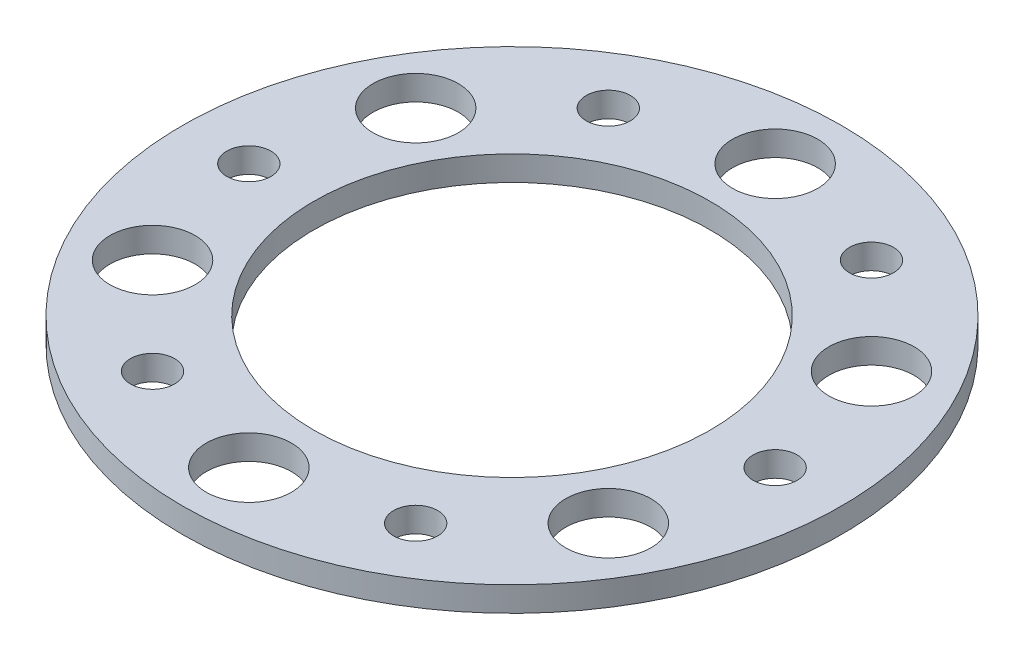
from build123d import *

# Parameters (mm, degrees)
SKETCH1_R             = 16.891
SKETCH1_R_2           = 10.16
BOSS_EXTRUDE1_DEPTH   = 1.27
SKETCH2_R             = 2.1844
CUT_EXTRUDE1_DEPTH    = 2.27
F_4_40_TAPPED_HOLE1_D = 2.2606


with BuildPart() as part:
    # Sketch1 → Boss-Extrude1 (new body)
    with BuildSketch(Plane(origin=(0, 0, 0), x_dir=(1, 0, 0), z_dir=(0, 1, 0))):
        Circle(SKETCH1_R)
        Circle(SKETCH1_R_2, mode=Mode.SUBTRACT)
    extrude(amount=BOSS_EXTRUDE1_DEPTH)

    # Sketch2 → Cut-Extrude1 (cut, through all)
    with BuildSketch(Plane(origin=(0, 1.27, 0), x_dir=(1, 0, 0), z_dir=(0, 1, 0))):
        with Locations((0, 13.4874)):
            Circle(SKETCH2_R)
        with Locations((-11.680431031, 6.7437)):
            Circle(SKETCH2_R)
        with Locations((-11.680431031, -6.7437)):
            Circle(SKETCH2_R)
        with Locations((0, -13.4874)):
            Circle(SKETCH2_R)
        with Locations((11.680431031, -6.7437)):
            Circle(SKETCH2_R)
        with Locations((11.680431031, 6.7437)):
            Circle(SKETCH2_R)
    extrude(amount=-CUT_EXTRUDE1_DEPTH, mode=Mode.SUBTRACT)

    # #4-40 Tapped Hole1 (through all)
    with Locations(Plane(origin=(0, 1.27, 0), x_dir=(1, 0, 0), z_dir=(0, 1, 0))):
        with Locations((0, 0), (-6.7437, 11.680431031), (6.7437, 11.680431031), (13.4874, 0), (6.7437, -11.680431031), (-6.7437, -11.680431031), (-13.4874, 0)):
            Hole(F_4_40_TAPPED_HOLE1_D / 2)


solid = part.part
